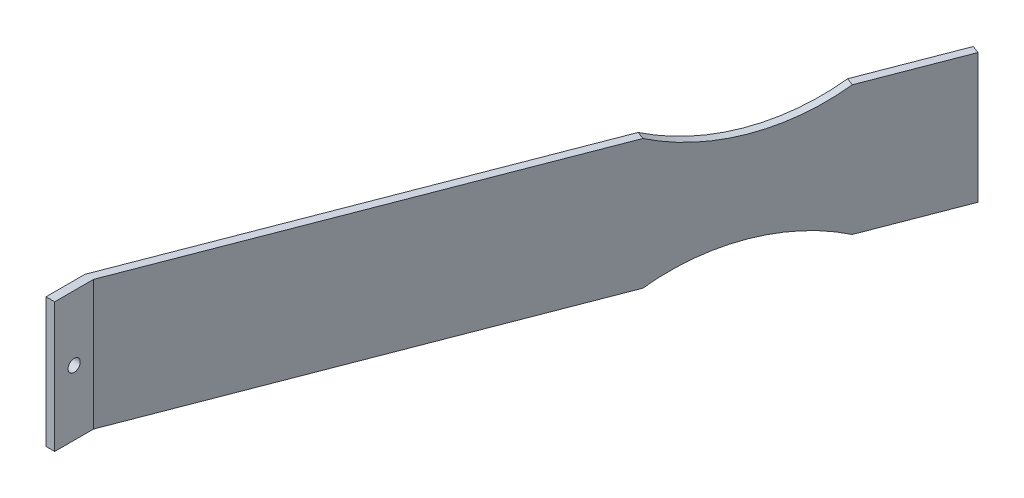
from build123d import *

# Parameters (mm, degrees)
BOSS_EXTRUDE1_DEPTH     = 50.8
SKETCH2_R               = 2.38125
CUT_EXTRUDE1_DEPTH      = 1
CUT_EXTRUDE1_DEPTH_BACK = 100.695
CUT_EXTRUDE2_DEPTH      = 96.340771022
CUT_EXTRUDE2_DEPTH_BACK = 94.451298519


with BuildPart() as part:
    # Sketch1 → Boss-Extrude1 (new body)
    with BuildSketch(Plane(origin=(0, 0, 0), x_dir=(1, 0, 0), z_dir=(0, 1, 0))):
        Polygon((-279.4, -117.475), (-182.668110184, 133.855439845), (-179.705, 132.715), (-275.9979581, -117.475), (-275.9979581, -132.715), (-279.4, -132.715), align=None)
    extrude(amount=BOSS_EXTRUDE1_DEPTH)

    # Sketch2 → Cut-Extrude1 (cut, two sides)
    with BuildSketch(Plane.ZY.offset(279.4)) as cut_extrude1_sk:
        with Locations((125.095, 25.4)):
            Circle(SKETCH2_R)
    extrude(amount=CUT_EXTRUDE1_DEPTH, mode=Mode.SUBTRACT)
    extrude(cut_extrude1_sk.sketch, amount=-CUT_EXTRUDE1_DEPTH_BACK, mode=Mode.SUBTRACT)

    # Sketch3 → Cut-Extrude2 (cut, two sides)
    with BuildSketch(Plane(origin=(-201.008455978, 0, -77.363998678), x_dir=(0.359193652, 0, -0.93326305), z_dir=(0.93326305, 0, 0.359193652))) as cut_extrude2_sk:
        with BuildLine():
            Line((-42.290889536, 50.8), (21.209110464, 50.8))
            ThreePointArc((21.209110464, 50.8), (-10.540889536, 43.18), (-42.290889536, 50.8))
        make_face()
        with BuildLine():
            Line((-42.290889536, 0), (21.209110464, 0))
            ThreePointArc((21.209110464, 0), (-10.540889536, 7.62), (-42.290889536, 0))
        make_face()
    extrude(amount=CUT_EXTRUDE2_DEPTH, mode=Mode.SUBTRACT)
    extrude(cut_extrude2_sk.sketch, amount=-CUT_EXTRUDE2_DEPTH_BACK, mode=Mode.SUBTRACT)


solid = part.part
